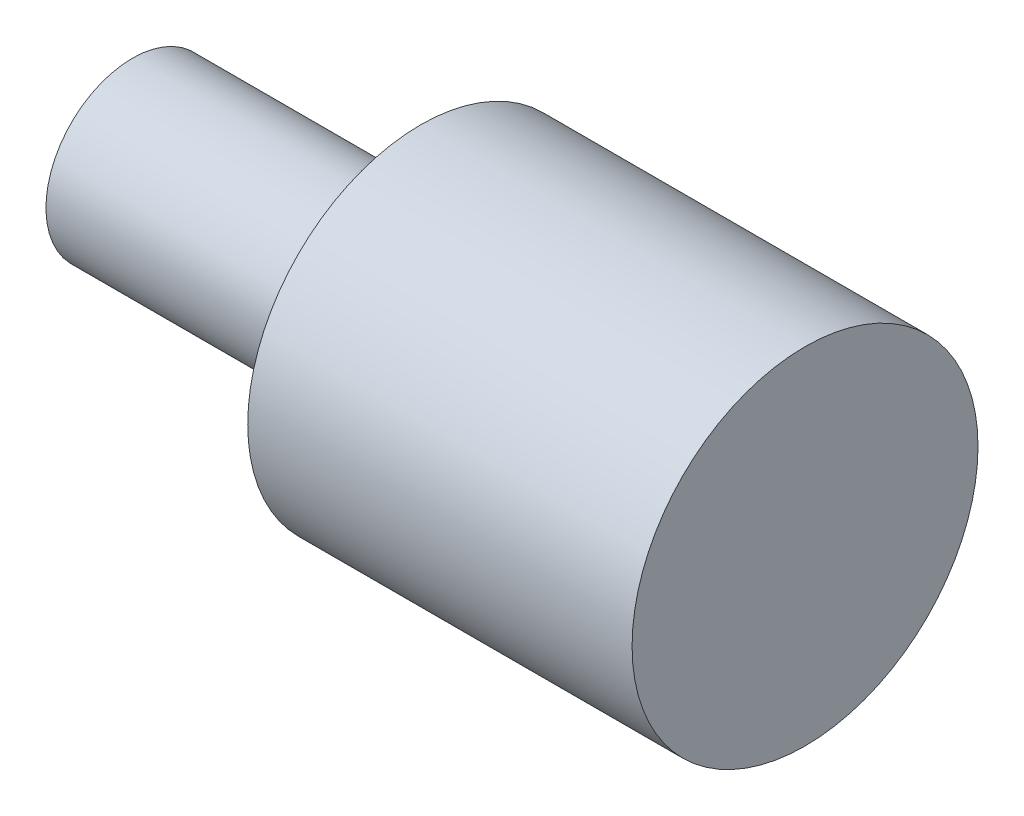
from build123d import *


with BuildPart() as part:
    # Эскиз1 → Повернуть1 (revolve)
    with BuildSketch(Plane.XY):
        Polygon((0, 0), (0, 0.9), (3, 0.9), (3, 1.8), (7, 1.8), (7, 0), align=None)
    revolve(axis=Axis((7, 0, 0), (-1, 0, 0)))


solid = part.part
